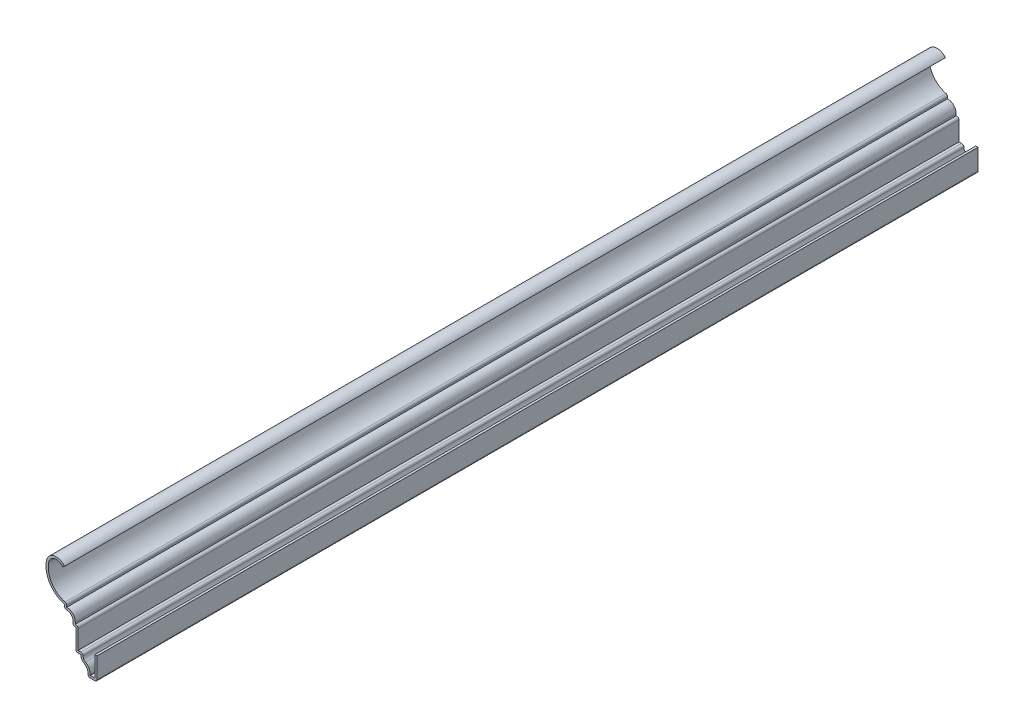
from build123d import *

# Parameters (mm, degrees)
EXTRUDE_THIN1_DEPTH = 492.125
FILLET1_R           = 1.27


with BuildPart() as part:
    # Sketch1 → Extrude-Thin1 (new body)
    with BuildSketch(Plane.XY):
        with BuildLine():
            Line((0, 0), (0, -12.7))
            Line((0, -12.7), (-5.159375, -12.7))
            Line((-5.159375, -12.7), (-5.159375, -10.842826643))
            ThreePointArc((-5.159375, -10.842826643), (-5.691086679, -8.858451643), (-7.14375, -7.405788321))
            ThreePointArc((-7.14375, -7.405788321), (-8.596413321, -5.953125), (-9.128125, -3.96875))
            Line((-9.128125, -3.96875), (-11.90625, -3.96875))
            Line((-11.90625, -3.96875), (-11.90625, 7.9375))
            Line((-11.90625, 7.9375), (-13.49375, 7.9375))
            Line((-13.49375, 7.9375), (-13.49375, 10.240343132))
            ThreePointArc((-13.49375, 10.240343132), (-15.016214309, 13.124180094), (-18.25625, 13.49375))
            Line((-18.25625, 13.49375), (-18.25625, 15.875))
            ThreePointArc((-18.25625, 15.875), (-26.477500212, 21.947406572), (-28.305018694, 32.003412381))
            ThreePointArc((-28.305018694, 32.003412381), (-23.995750741, 36.384342306), (-18.25625, 34.18878576))
            Line((-18.25625, 34.18878576), (-19.28547828, 33.444750043))
            ThreePointArc((-19.28547828, 33.444750043), (-23.725863862, 35.143350335), (-27.059744656, 31.754027996))
            ThreePointArc((-27.059744656, 31.754027996), (-25.135637157, 22.212936626), (-16.98625, 16.891085148))
            Line((-16.98625, 16.891085148), (-16.98625, 15.002843132))
            ThreePointArc((-16.98625, 15.002843132), (-13.618653955, 13.607939177), (-12.22375, 10.240343132))
            Line((-12.22375, 10.240343132), (-12.22375, 9.2075))
            Line((-12.22375, 9.2075), (-10.63625, 9.2075))
            Line((-10.63625, 9.2075), (-10.63625, -2.69875))
            Line((-10.63625, -2.69875), (-7.540625, -2.69875))
            ThreePointArc((-7.540625, -2.69875), (-7.754050035, -4.710985155), (-6.50875, -6.305936058))
            ThreePointArc((-6.50875, -6.305936058), (-4.591234416, -8.223451643), (-3.889375, -10.842826643))
            Line((-3.889375, -10.842826643), (-3.889375, -11.43))
            Line((-3.889375, -11.43), (-1.27, -11.43))
            Line((-1.27, -11.43), (-1.27, 0))
            Line((-1.27, 0), (0, 0))
        make_face()
    extrude(amount=-EXTRUDE_THIN1_DEPTH)

    # Fillet1
    fillet1_edges = [part.edges().sort_by_distance(p)[0] for p in [
        (-16.98625, 16.891085148, -246.0625),
        (-10.63625, 9.2075, -246.0625),
        (-7.540625, -2.69875, -246.0625),
        (0, -12.7, -246.0625),
        (-5.159375, -12.7, -246.0625),
        (-11.90625, -3.96875, -246.0625),
        (-13.49375, 7.9375, -246.0625),
        (-18.25625, 13.49375, -246.0625),
    ]]
    fillet(fillet1_edges, radius=FILLET1_R)


solid = part.part
